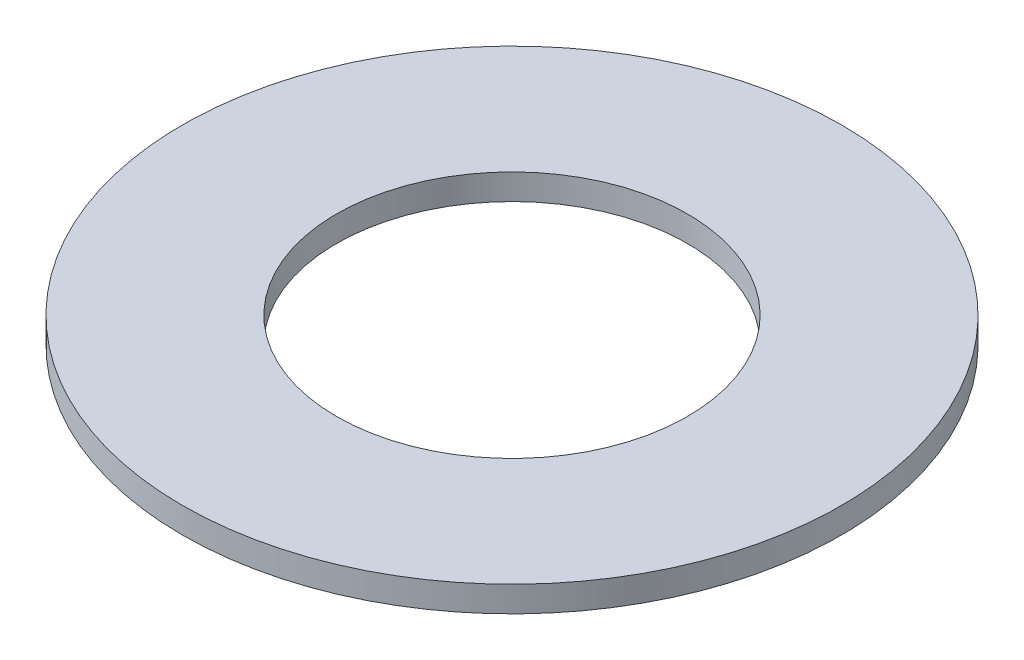
from build123d import *

# Parameters (mm, degrees)
SKETCH1_R           = 7.7
SKETCH1_R_2         = 4.1
BOSS_EXTRUDE1_DEPTH = 0.6


with BuildPart() as part:
    # Sketch1 → Boss-Extrude1 (new body)
    with BuildSketch(Plane(origin=(0, 0, 0), x_dir=(1, 0, 0), z_dir=(0, 1, 0))):
        Circle(SKETCH1_R)
        Circle(SKETCH1_R_2, mode=Mode.SUBTRACT)
    extrude(amount=BOSS_EXTRUDE1_DEPTH)


solid = part.part
